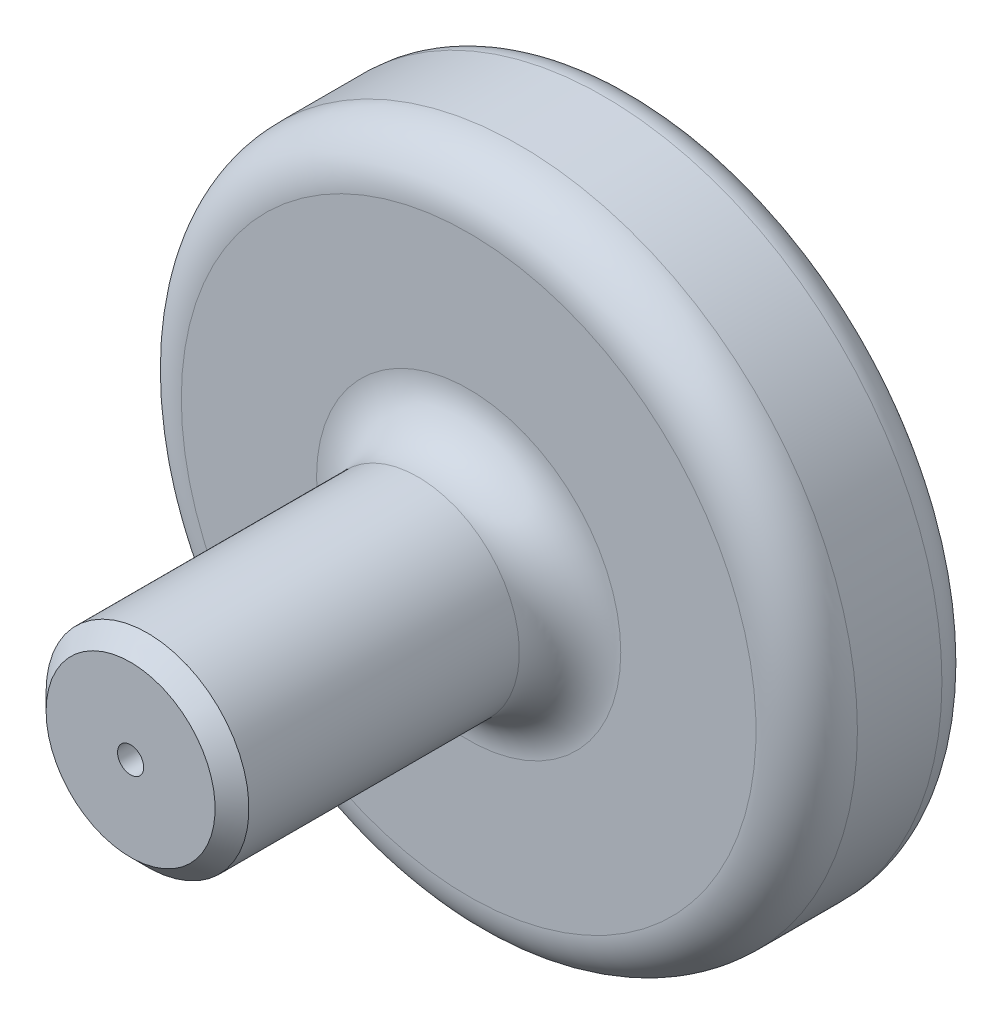
from build123d import *

# Parameters (mm, degrees)
FILLET1_R          = 10
CHAMFER1_SIZE      = 5
FILLET2_R          = 15
SKETCH2_R          = 3.860242373
CUT_EXTRUDE1_DEPTH = 151


with BuildPart() as part:
    # Sketch1 → Revolve1 (revolve)
    with BuildSketch(Plane(origin=(0, 0, 0), x_dir=(1, 0, 0), z_dir=(0, 1, 0)), mode=Mode.PRIVATE) as revolve1_sk:
        Polygon((0, 0), (100, 0), (100, -50), (30, -50), (30, -150), (0, -150), align=None)
    revolve(revolve1_sk.sketch.rotate(Axis((0, 0, -26.959763618), (0, 0, 1)), 180), axis=Axis((0, 0, -26.959763618), (0, 0, 1)))  # turned: the seam where the file's is

    # Fillet1
    fillet1_edges = [part.edges().sort_by_distance(p)[0] for p in [
        (100, 0, 0),
    ]]
    fillet(fillet1_edges, radius=FILLET1_R)

    # Chamfer1
    chamfer1_edges = [part.edges().sort_by_distance(p)[0] for p in [
        (30, 0, 150),
    ]]
    chamfer(chamfer1_edges, length=CHAMFER1_SIZE)

    # Fillet2
    fillet2_edges = [part.edges().sort_by_distance(p)[0] for p in [
        (30, 0, 50),
        (100, 0, 50),
    ]]
    fillet(fillet2_edges, radius=FILLET2_R)

    # Sketch2 → Cut-Extrude1 (cut, through all)
    with BuildSketch(Plane.XY.offset(150)):
        Circle(SKETCH2_R)
    extrude(amount=-CUT_EXTRUDE1_DEPTH, mode=Mode.SUBTRACT)


solid = part.part
